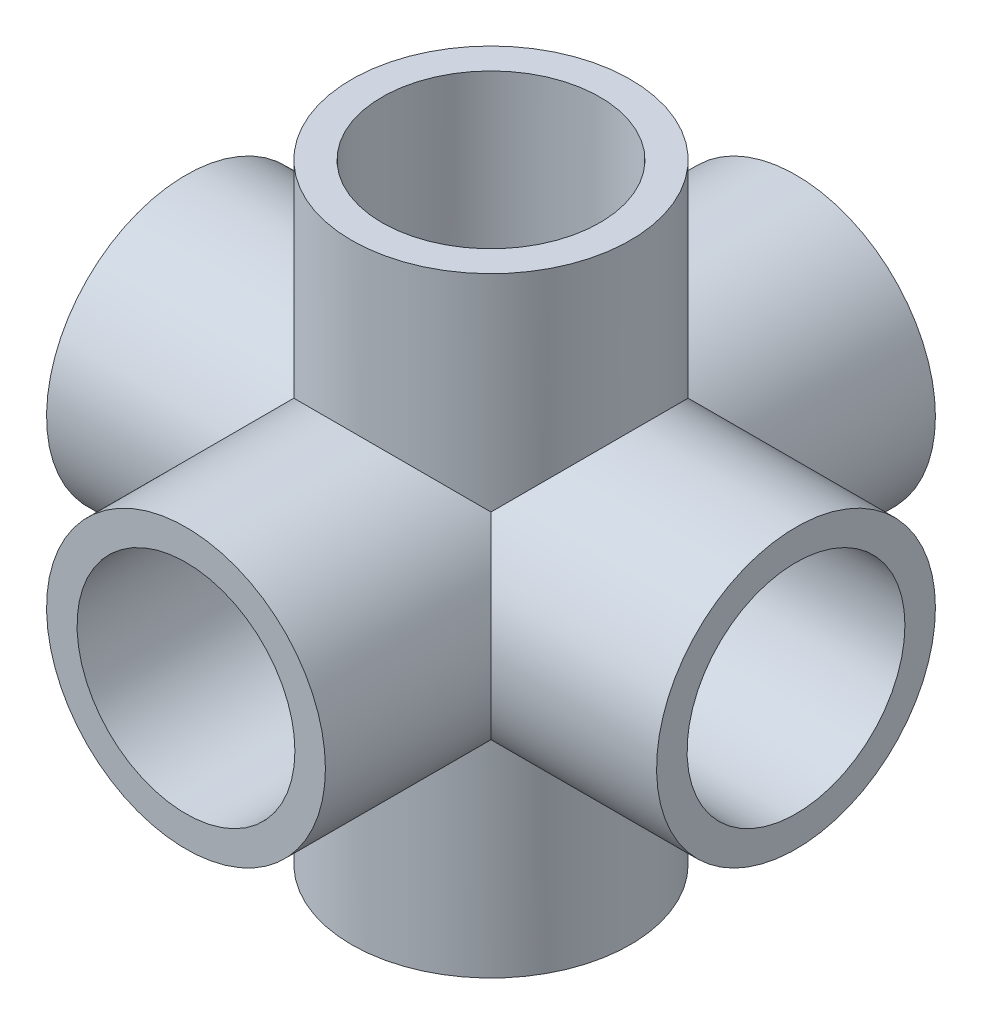
from build123d import *

# Parameters (mm, degrees)
SKETCH_1_R      = 16
SKETCH_1_R_2    = 12.5
EXTRUDE_1_DEPTH = 35
SKETCH_2_R      = 16
SKETCH_2_R_2    = 12.5
EXTRUDE_2_DEPTH = 35
SKETCH_4_R      = 16
SKETCH_4_R_2    = 12.5
EXTRUDE_3_DEPTH = 35


with BuildPart() as part:
    # 草图1 → 凸台-拉伸1 (new body, symmetric)
    with BuildSketch(Plane.XY):
        Circle(SKETCH_1_R)
        Circle(SKETCH_1_R_2, mode=Mode.SUBTRACT)
    extrude(amount=EXTRUDE_1_DEPTH, both=True)

    # 草图2 → 凸台-拉伸2 (add, symmetric)
    with BuildSketch(Plane(origin=(0, 0, 0), x_dir=(0, 0, -1), z_dir=(1, 0, 0))):
        Circle(SKETCH_2_R)
        Circle(SKETCH_2_R_2, mode=Mode.SUBTRACT)
    extrude(amount=EXTRUDE_2_DEPTH, both=True)

    # 草图4 → 凸台-拉伸3 (add, symmetric)
    with BuildSketch(Plane(origin=(0, 0, 0), x_dir=(1, 0, 0), z_dir=(0, 1, 0))):
        Circle(SKETCH_4_R)
        Circle(SKETCH_4_R_2, mode=Mode.SUBTRACT)
    extrude(amount=EXTRUDE_3_DEPTH, both=True)


solid = part.part
